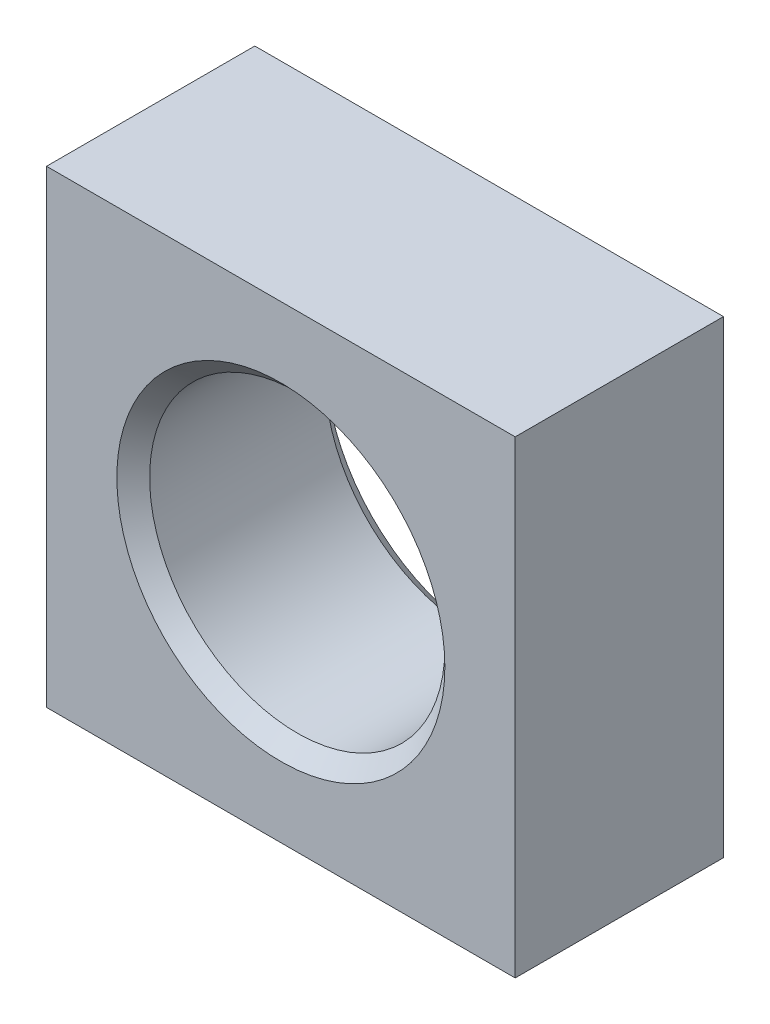
from build123d import *

# Parameters (mm, degrees)
SKETCH_W            = 28.575
SKETCH_H            = 28.575
BOSS_EXTRUDE1_DEPTH = 12.7


with BuildPart() as part:
    # Sketch → Boss-Extrude1 (new body)
    with BuildSketch(Plane.XY):
        Rectangle(SKETCH_W, SKETCH_H)
    extrude(amount=-BOSS_EXTRUDE1_DEPTH)

    # Sketch1 → M20x2.0 Tapped Hole1 (revolve, cut)
    with BuildSketch(Plane(origin=(0, 0, 0), x_dir=(0, -1, 0), z_dir=(1, 0, 0))):
        Polygon((0, 0), (0, 12.7), (10, 12.7), (9, 11.7), (9, 1), (10, 0), align=None)
    revolve(axis=Axis((0, 0, 6.35), (0, 0, -1)), mode=Mode.SUBTRACT)


solid = part.part
